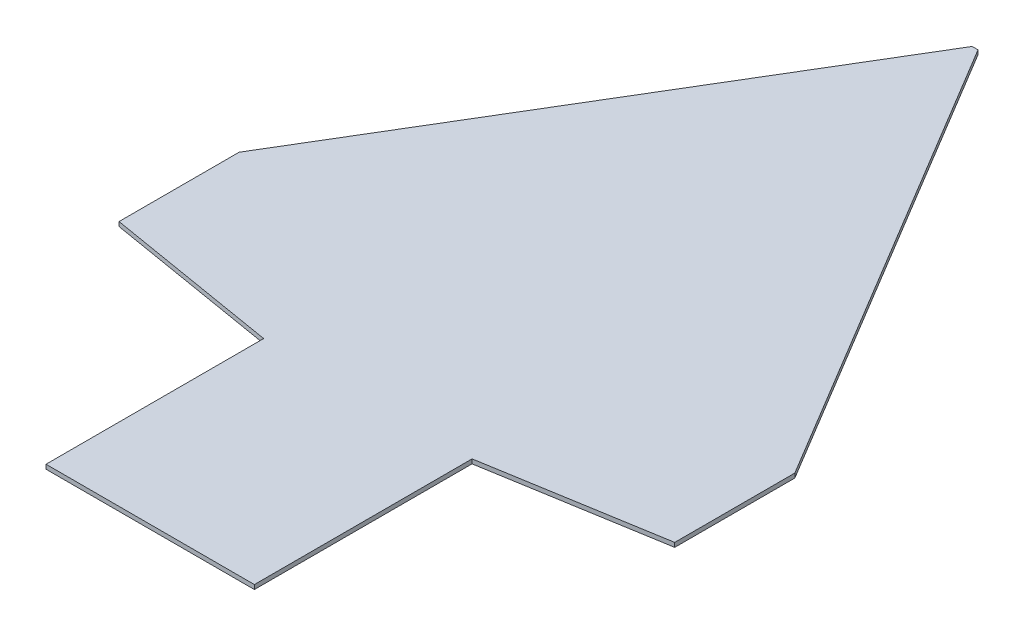
from build123d import *

# Parameters (mm, degrees)
BOSS_EXTRUDE1_DEPTH = 2.54


with BuildPart() as part:
    # Sketch1 → Boss-Extrude1 (new body)
    with BuildSketch(Plane(origin=(0, 0, 0), x_dir=(1, 0, 0), z_dir=(0, 1, 0))):
        Polygon((25.131016425, 82.213636442), (21.702924549, 82.213636442), (-139.143029513, -185.803434051), (-139.143029513, -256.063525811), (-37.543029513, -273.034455318), (-37.543029513, -400.386363558), (84.376970487, -400.386363558), (84.376970487, -273.034455318), (185.976970487, -256.063525811), (185.976970487, -185.803434051), align=None)
    extrude(amount=BOSS_EXTRUDE1_DEPTH)


solid = part.part
